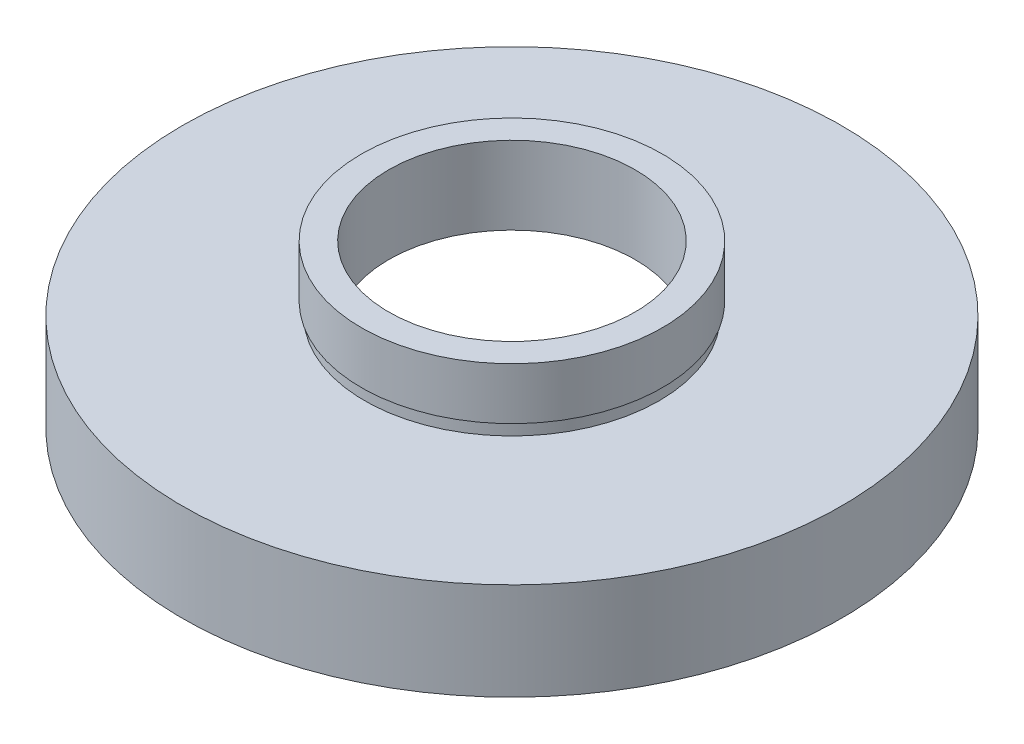
from build123d import *


with BuildPart() as part:
    # 草图1 → 旋转1 (revolve)
    with BuildSketch(Plane.XY, mode=Mode.PRIVATE) as revolve_1_sk:
        Polygon((20.5, 0), (20.5, 5.5), (21.1, 5.5), (21.1, 6.5), (9.5, 6.5), (9.5, 12.5), (11.6, 12.5), (11.6, 8.5), (11.35, 8.5), (11.35, 7.5), (25.4, 7.5), (25.4, 0), align=None)
    revolve(revolve_1_sk.sketch.rotate(Axis((0, 16.886018237, 0), (0, -1, 0)), 180), axis=Axis((0, 16.886018237, 0), (0, -1, 0)))  # turned: the seam where the file's is


solid = part.part
